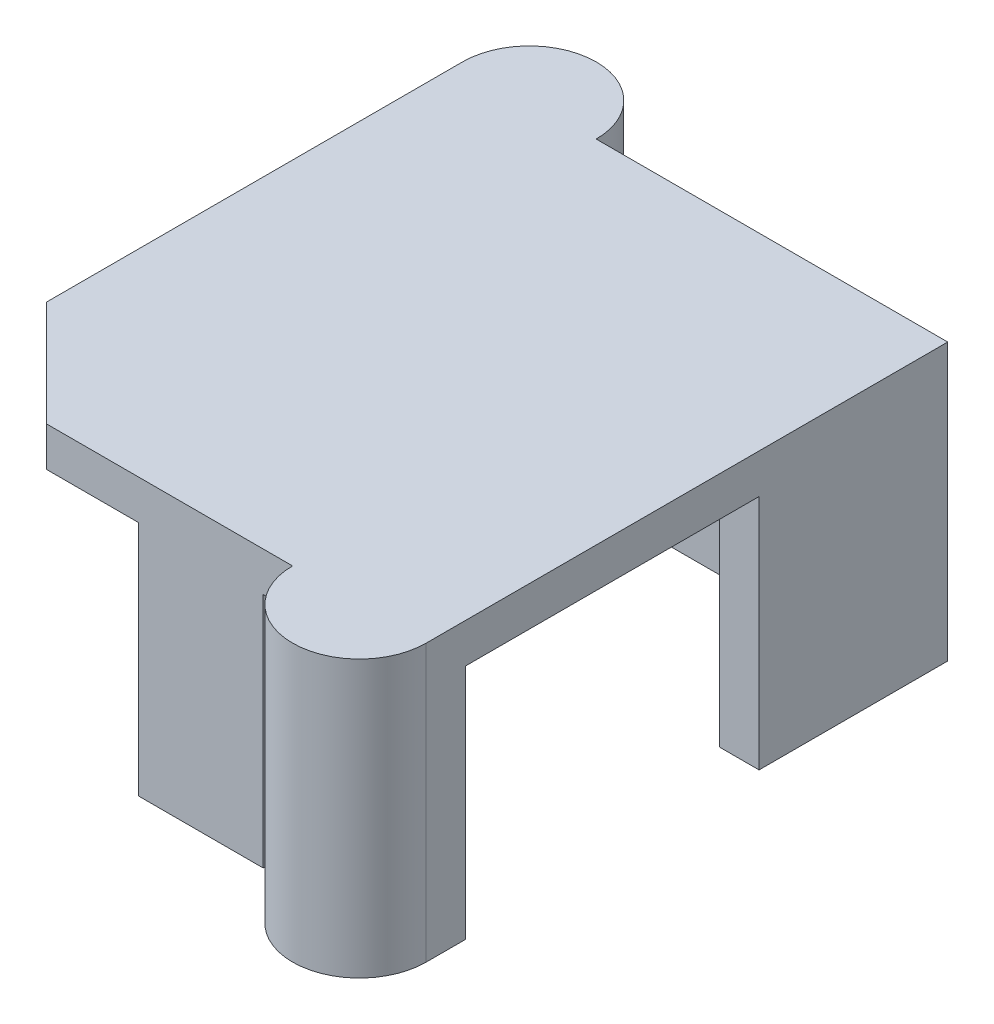
from build123d import *

# Parameters (mm, degrees)
SKETCH_1_W             = 15.44
SKETCH_1_H             = 16.82
EXTRUDE_1_DEPTH        = 9
SHELL_3_T              = 1.5
SKETCH_2_W             = 1.5
SKETCH_2_H             = 11.15
CUT_EXTRUDE_1_DEPTH    = 9
SKETCH_3_W             = 7.5
SKETCH_3_H             = 8.5
CUT_EXTRUDE_2_DEPTH    = 9
SKETCH_4_W             = 1.12
SKETCH_4_H             = 1.5
CUT_EXTRUDE_3_DEPTH    = 9
CHAMFER_1_SIZE         = 4
EXTRUDE_2_REACH        = 19.131
M1_4X0_3_1_D           = 1.1
M1_4X0_3_1_DEPTH       = 7.66952666
M1_4X0_3_1_CSINK_D     = 1.15
M1_4X0_3_1_CSINK_ANGLE = 90
M1_4X0_3_1_TIP         = 0.33047334


with BuildPart() as part:
    # 草图1 → 凸台-拉伸1 (new body)
    with BuildSketch(Plane(origin=(0, 0, 0), x_dir=(1, 0, 0), z_dir=(0, 1, 0))):
        Rectangle(SKETCH_1_W, SKETCH_1_H)
    extrude(amount=EXTRUDE_1_DEPTH)

    # 抽壳3
    shell_3_openings = [part.faces().sort_by_distance(p)[0] for p in [
        (0, 0, 0),
    ]]
    offset(amount=SHELL_3_T, openings=shell_3_openings, kind=Kind.INTERSECTION)

    # 草图2 → 切除-拉伸1 (cut)
    with BuildSketch(Plane.XZ):
        with Locations((8.47, 2.835)):
            Rectangle(SKETCH_2_W, SKETCH_2_H)
    extrude(amount=-CUT_EXTRUDE_1_DEPTH, mode=Mode.SUBTRACT)

    # 草图3 → 切除-拉伸2 (cut)
    with BuildSketch(Plane.XZ):
        with Locations((-5.47, 5.66)):
            Rectangle(SKETCH_3_W, SKETCH_3_H)
    extrude(amount=-CUT_EXTRUDE_2_DEPTH, mode=Mode.SUBTRACT)

    # 草图4 → 切除-拉伸3 (cut)
    with BuildSketch(Plane.XZ):
        with Locations((3.58, 9.16)):
            Rectangle(SKETCH_4_W, SKETCH_4_H)
        with Locations((3.58, -9.16)):
            Rectangle(SKETCH_4_W, SKETCH_4_H)
    extrude(amount=-CUT_EXTRUDE_3_DEPTH, mode=Mode.SUBTRACT)

    # 倒角1
    chamfer_1_edges = [part.edges().sort_by_distance(p)[0] for p in [
        (-9.22, 9.75, 9.91),
    ]]
    chamfer(chamfer_1_edges, length=CHAMFER_1_SIZE)

    # 凸台-拉伸2: up to this face of the body (flat: up to its plane)
    extrude_2_end = Plane(part.part.faces().sort_by_distance((0.176494327, 10.5, -0.191935716))[0])
    # 草图5 → 凸台-拉伸2 (add, up to the picked face)
    with BuildSketch(Plane.XZ, mode=Mode.PRIVATE) as extrude_2_sk1:
        with BuildLine():
            Line((9.22, 9.91), (4.14, 9.91))
            ThreePointArc((4.14, 9.91), (6.68, 12.45), (9.22, 9.91))
        make_face()
    extrude_2_tool1 = split(extrude(extrude_2_sk1.sketch, amount=-EXTRUDE_2_REACH, mode=Mode.PRIVATE), bisect_by=extrude_2_end, keep=Keep.BOTH, mode=Mode.PRIVATE)
    # 草图5 → 凸台-拉伸2 (add, up to the picked face)
    with BuildSketch(Plane.XZ, mode=Mode.PRIVATE) as extrude_2_sk2:
        with BuildLine():
            Line((-9.22, -9.91), (-4.14, -9.91))
            ThreePointArc((-4.14, -9.91), (-6.68, -12.45), (-9.22, -9.91))
        make_face()
    extrude_2_tool2 = split(extrude(extrude_2_sk2.sketch, amount=-EXTRUDE_2_REACH, mode=Mode.PRIVATE), bisect_by=extrude_2_end, keep=Keep.BOTH, mode=Mode.PRIVATE)
    add(extrude_2_tool1.solids().sort_by(Axis((6.68, 0, 10.988009), (0, 1, 0)))[0])
    add(extrude_2_tool2.solids().sort_by(Axis((-6.68, 0, -10.988009), (0, 1, 0)))[0])

    # M1.4X0.3 螺纹孔的螺纹孔钻头1
    with Locations(Plane(origin=(0, 0, 0), x_dir=(-1, 0, 0), z_dir=(0, -1, 0))):
        with Locations((6.68, 10.63), (-6.68, -10.63)):
            CounterSinkHole(M1_4X0_3_1_D / 2, M1_4X0_3_1_CSINK_D / 2, depth=M1_4X0_3_1_DEPTH, counter_sink_angle=M1_4X0_3_1_CSINK_ANGLE)
            with Locations((0, 0, -(M1_4X0_3_1_DEPTH + M1_4X0_3_1_TIP / 2))):  # 118° drill point
                Cone(0, M1_4X0_3_1_D / 2, M1_4X0_3_1_TIP, mode=Mode.SUBTRACT)


solid = part.part
